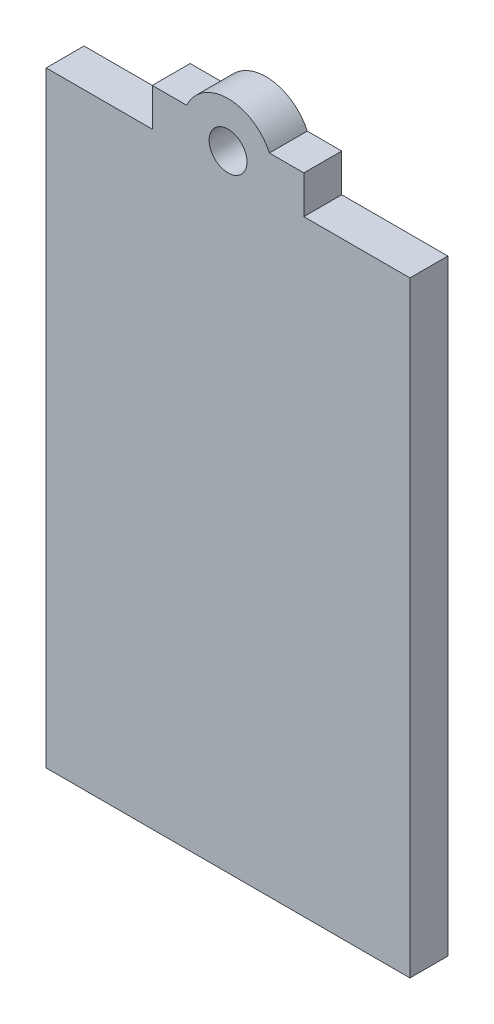
from build123d import *

# Parameters (mm, degrees)
SKETCH1_W           = 48
SKETCH1_H           = 100
BOSS_EXTRUDE1_DEPTH = 5
SKETCH2_W           = 20
SKETCH2_H           = 5
BOSS_EXTRUDE2_DEPTH = 5
SKETCH3_R           = 6
BOSS_EXTRUDE3_DEPTH = 5
SKETCH4_R           = 2.5
CUT_EXTRUDE1_DEPTH  = 5
SKETCH5_W           = 53.859094163
SKETCH5_H           = 28.820783856
CUT_EXTRUDE2_DEPTH  = 10


with BuildPart() as part:
    # Sketch1 → Boss-Extrude1 (new body)
    with BuildSketch(Plane.XY):
        Rectangle(SKETCH1_W, SKETCH1_H)
    extrude(amount=BOSS_EXTRUDE1_DEPTH)

    # Sketch2 → Boss-Extrude2 (add)
    with BuildSketch(Plane(origin=(0, 50, 0), x_dir=(1, 0, 0), z_dir=(0, 1, 0))):
        with Locations((0, -2.5)):
            Rectangle(SKETCH2_W, SKETCH2_H)
    boss_extrude2 = extrude(amount=BOSS_EXTRUDE2_DEPTH)

    # Mirror1: Boss-Extrude2 across plane
    add(boss_extrude2.mirror(Plane.ZX))

    # Sketch3 → Boss-Extrude3 (add)
    with BuildSketch(Plane.XY.offset(5)):
        with Locations((0, 52.5)):
            Circle(SKETCH3_R)
    boss_extrude3 = extrude(amount=-BOSS_EXTRUDE3_DEPTH)

    # Sketch4 → Cut-Extrude1 (cut)
    with BuildSketch(Plane.XY.offset(5)):
        with Locations((0, 52.5)):
            Circle(SKETCH4_R)
    cut_extrude1 = extrude(amount=-CUT_EXTRUDE1_DEPTH, mode=Mode.SUBTRACT)

    # Mirror2: Boss-Extrude3, Cut-Extrude1 across plane
    add(boss_extrude3.mirror(Plane.ZX))
    add(cut_extrude1.mirror(Plane.ZX), mode=Mode.SUBTRACT)

    # Sketch5 → Cut-Extrude2 (cut)
    with BuildSketch(Plane.XY.offset(5)):
        with Locations((2.929547082, -44.410391928)):
            Rectangle(SKETCH5_W, SKETCH5_H)
    extrude(amount=-CUT_EXTRUDE2_DEPTH, mode=Mode.SUBTRACT)


solid = part.part
